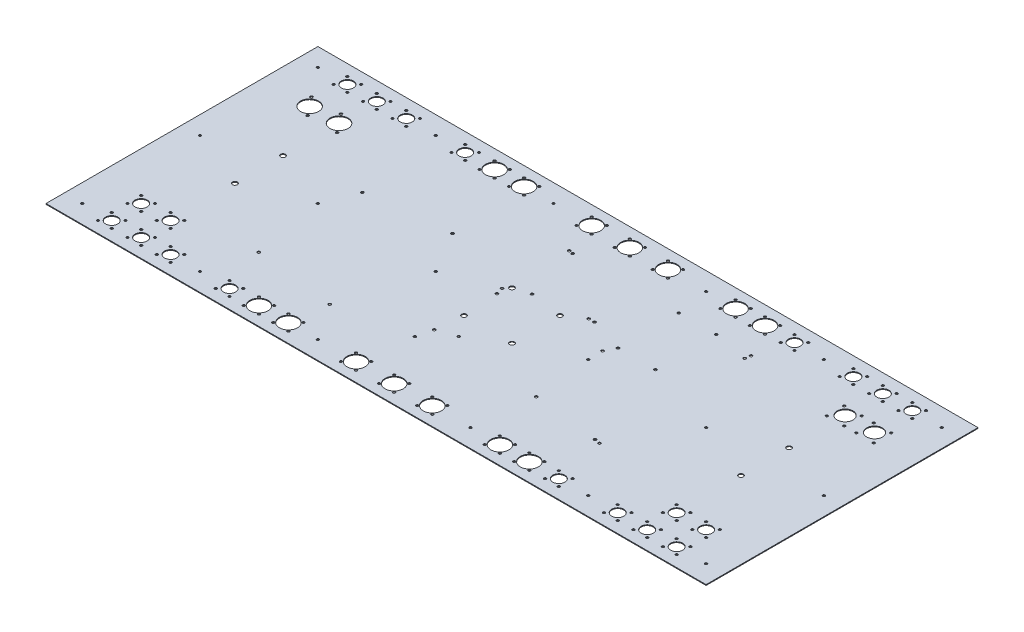
from build123d import *

# Parameters (mm, degrees)
MAIN_PLATE_W        = 874
MAIN_PLATE_H        = 360
BOSS_EXTRUDE1_DEPTH = 1.016
MAIN_HOLES_R        = 1.6
MAIN_HOLES_R_2      = 3.175
CUT_EXTRUDE1_DEPTH  = 473.620389167
FAN_R               = 1.6
FAN_R_2             = 12
CUT_EXTRUDE2_DEPTH  = 474.008271082
NTYPE_R             = 8
NTYPE_R_2           = 1.6
CUT_EXTRUDE3_DEPTH  = 473.620389167
ETHERNET_R          = 12
ETHERNET_R_2        = 1.755
CUT_EXTRUDE6_DEPTH  = 10
POWER_R             = 10.4521
POWER_R_2           = 1.5875
CUT_EXTRUDE7_DEPTH  = 10
ADS9_EVAL_R         = 1.75
CUT_EXTRUDE8_DEPTH  = 10


with BuildPart() as part:
    # main_plate → Boss-Extrude1 (new body)
    with BuildSketch(Plane(origin=(0, 0, 0), x_dir=(1, 0, 0), z_dir=(0, 1, 0))):
        Rectangle(MAIN_PLATE_W, MAIN_PLATE_H)
    extrude(amount=BOSS_EXTRUDE1_DEPTH)

    # main_holes → Cut-Extrude1 (cut, through all)
    with BuildSketch(Plane(origin=(0, 1.016, 0), x_dir=(1, 0, 0), z_dir=(0, 1, 0))):
        with Locations(Location((-413, 156, 0), (0, 0, 270))):
            Circle(MAIN_HOLES_R)
        with Locations(Location((-335, 31.805896398, 0), (0, 0, 270))):
            Circle(MAIN_HOLES_R_2)
        with Locations(Location((-335, -31.805896398, 0), (0, 0, 90))):
            Circle(MAIN_HOLES_R_2)
        with Locations(Location((-257, 156, 0), (0, 0, 270))):
            Circle(MAIN_HOLES_R)
        with Locations(Location((-101, 156, 0), (0, 0, 270))):
            Circle(MAIN_HOLES_R)
        with Locations(Location((-257, 0, 0), (0, 0, 270))):
            Circle(MAIN_HOLES_R)
        with Locations(Location((-101, 0, 0), (0, 0, 270))):
            Circle(MAIN_HOLES_R)
        with Locations(Location((-257, -156, 0), (0, 0, 270))):
            Circle(MAIN_HOLES_R)
        with Locations(Location((-101, -156, 0), (0, 0, 270))):
            Circle(MAIN_HOLES_R)
        with Locations(Location((-413, 0, 0), (0, 0, 270))):
            Circle(MAIN_HOLES_R)
        with Locations(Location((-413, -156, 0), (0, 0, 270))):
            Circle(MAIN_HOLES_R)
        with Locations(Location((-31.75, 31.75, 0), (0, 0, 270))):
            Circle(MAIN_HOLES_R_2)
        with Locations(Location((-31.75, -31.75, 0), (0, 0, 90))):
            Circle(MAIN_HOLES_R_2)
        with Locations(Location((31.75, -31.75, 0), (0, 0, 270))):
            Circle(MAIN_HOLES_R_2)
        with Locations(Location((31.75, 31.75, 0), (0, 0, 90))):
            Circle(MAIN_HOLES_R_2)
        with Locations(Location((413, -156, 0), (0, 0, 90))):
            Circle(MAIN_HOLES_R)
        with Locations(Location((413, 0, 0), (0, 0, 90))):
            Circle(MAIN_HOLES_R)
        with Locations(Location((101, -156, 0), (0, 0, 90))):
            Circle(MAIN_HOLES_R)
        with Locations(Location((257, -156, 0), (0, 0, 90))):
            Circle(MAIN_HOLES_R)
        with Locations(Location((101, 0, 0), (0, 0, 90))):
            Circle(MAIN_HOLES_R)
        with Locations(Location((257, 0, 0), (0, 0, 90))):
            Circle(MAIN_HOLES_R)
        with Locations(Location((101, 156, 0), (0, 0, 90))):
            Circle(MAIN_HOLES_R)
        with Locations(Location((257, 156, 0), (0, 0, 90))):
            Circle(MAIN_HOLES_R)
        with Locations(Location((335, -31.805896398, 0), (0, 0, 270))):
            Circle(MAIN_HOLES_R_2)
        with Locations(Location((335, 31.805896398, 0), (0, 0, 90))):
            Circle(MAIN_HOLES_R_2)
        with Locations(Location((413, 156, 0), (0, 0, 90))):
            Circle(MAIN_HOLES_R)
    extrude(amount=-CUT_EXTRUDE1_DEPTH, mode=Mode.SUBTRACT)

    # fan → Cut-Extrude2 (cut, through all)
    with BuildSketch(Plane(origin=(0, 1.016, 1.016), x_dir=(1, 0, 0), z_dir=(0, 1, 0))):
        with Locations(Location((130, -144.984, 0), (0, 0, 270))):
            Circle(FAN_R)
        with Locations(Location((150, -144.984, 0), (0, 0, 270))):
            Circle(FAN_R)
        with Locations(Location((150, -164.984, 0), (0, 0, 270))):
            Circle(FAN_R)
        with Locations(Location((130, -164.984, 0), (0, 0, 270))):
            Circle(FAN_R)
        with Locations(Location((140, -154.984, 0), (0, 0, 270))):
            Circle(FAN_R_2)
        with Locations(Location((169, -144.984, 0), (0, 0, 270))):
            Circle(FAN_R)
        with Locations(Location((189, -144.984, 0), (0, 0, 270))):
            Circle(FAN_R)
        with Locations(Location((189, -164.984, 0), (0, 0, 270))):
            Circle(FAN_R)
        with Locations(Location((169, -164.984, 0), (0, 0, 270))):
            Circle(FAN_R)
        with Locations(Location((179, -154.984, 0), (0, 0, 270))):
            Circle(FAN_R_2)
        with Locations(Location((-10, -144.984, 0), (0, 0, 270))):
            Circle(FAN_R)
        with Locations(Location((10, -144.984, 0), (0, 0, 270))):
            Circle(FAN_R)
        with Locations(Location((10, -164.984, 0), (0, 0, 270))):
            Circle(FAN_R)
        with Locations(Location((-10, -164.984, 0), (0, 0, 270))):
            Circle(FAN_R)
        with Locations(Location((0, -154.984, 0), (0, 0, 270))):
            Circle(FAN_R_2)
        with Locations(Location((-60.5, -144.984, 0), (0, 0, 270))):
            Circle(FAN_R)
        with Locations(Location((-40.5, -144.984, 0), (0, 0, 270))):
            Circle(FAN_R)
        with Locations(Location((-40.5, -164.984, 0), (0, 0, 270))):
            Circle(FAN_R)
        with Locations(Location((-60.5, -164.984, 0), (0, 0, 270))):
            Circle(FAN_R)
        with Locations(Location((-50.5, -154.984, 0), (0, 0, 270))):
            Circle(FAN_R_2)
        with Locations(Location((40.5, -144.984, 0), (0, 0, 270))):
            Circle(FAN_R)
        with Locations(Location((60.5, -144.984, 0), (0, 0, 270))):
            Circle(FAN_R)
        with Locations(Location((60.5, -164.984, 0), (0, 0, 270))):
            Circle(FAN_R)
        with Locations(Location((40.5, -164.984, 0), (0, 0, 270))):
            Circle(FAN_R)
        with Locations(Location((50.5, -154.984, 0), (0, 0, 270))):
            Circle(FAN_R_2)
        with Locations(Location((-10, 167.016, 0), (0, 0, 270))):
            Circle(FAN_R)
        with Locations(Location((10, 167.016, 0), (0, 0, 270))):
            Circle(FAN_R)
        with Locations(Location((10, 147.016, 0), (0, 0, 270))):
            Circle(FAN_R)
        with Locations(Location((-10, 147.016, 0), (0, 0, 270))):
            Circle(FAN_R)
        with Locations(Location((0, 157.016, 0), (0, 0, 270))):
            Circle(FAN_R_2)
        with Locations(Location((-60.5, 167.016, 0), (0, 0, 270))):
            Circle(FAN_R)
        with Locations(Location((-40.5, 167.016, 0), (0, 0, 270))):
            Circle(FAN_R)
        with Locations(Location((-40.5, 147.016, 0), (0, 0, 270))):
            Circle(FAN_R)
        with Locations(Location((-60.5, 147.016, 0), (0, 0, 270))):
            Circle(FAN_R)
        with Locations(Location((-50.5, 157.016, 0), (0, 0, 270))):
            Circle(FAN_R_2)
        with Locations(Location((40.5, 167.016, 0), (0, 0, 270))):
            Circle(FAN_R)
        with Locations(Location((60.5, 167.016, 0), (0, 0, 270))):
            Circle(FAN_R)
        with Locations(Location((60.5, 147.016, 0), (0, 0, 270))):
            Circle(FAN_R)
        with Locations(Location((40.5, 147.016, 0), (0, 0, 270))):
            Circle(FAN_R)
        with Locations(Location((50.5, 157.016, 0), (0, 0, 270))):
            Circle(FAN_R_2)
        with Locations(Location((-189, -144.984, 0), (0, 0, 270))):
            Circle(FAN_R)
        with Locations(Location((-169, -144.984, 0), (0, 0, 270))):
            Circle(FAN_R)
        with Locations(Location((-169, -164.984, 0), (0, 0, 270))):
            Circle(FAN_R)
        with Locations(Location((-189, -164.984, 0), (0, 0, 270))):
            Circle(FAN_R)
        with Locations(Location((-179, -154.984, 0), (0, 0, 270))):
            Circle(FAN_R_2)
        with Locations(Location((-150, -144.984, 0), (0, 0, 270))):
            Circle(FAN_R)
        with Locations(Location((-130, -144.984, 0), (0, 0, 270))):
            Circle(FAN_R)
        with Locations(Location((-130, -164.984, 0), (0, 0, 270))):
            Circle(FAN_R)
        with Locations(Location((-150, -164.984, 0), (0, 0, 270))):
            Circle(FAN_R)
        with Locations(Location((-140, -154.984, 0), (0, 0, 270))):
            Circle(FAN_R_2)
        with Locations(Location((-189, 167.016, 0), (0, 0, 270))):
            Circle(FAN_R)
        with Locations(Location((-169, 167.016, 0), (0, 0, 270))):
            Circle(FAN_R)
        with Locations(Location((-169, 147.016, 0), (0, 0, 270))):
            Circle(FAN_R)
        with Locations(Location((-189, 147.016, 0), (0, 0, 270))):
            Circle(FAN_R)
        with Locations(Location((-179, 157.016, 0), (0, 0, 270))):
            Circle(FAN_R_2)
        with Locations(Location((-150, 167.016, 0), (0, 0, 270))):
            Circle(FAN_R)
        with Locations(Location((-130, 167.016, 0), (0, 0, 270))):
            Circle(FAN_R)
        with Locations(Location((-130, 147.016, 0), (0, 0, 270))):
            Circle(FAN_R)
        with Locations(Location((-150, 147.016, 0), (0, 0, 270))):
            Circle(FAN_R)
        with Locations(Location((-140, 157.016, 0), (0, 0, 270))):
            Circle(FAN_R_2)
        with Locations(Location((130, 167.016, 0), (0, 0, 270))):
            Circle(FAN_R)
        with Locations(Location((150, 167.016, 0), (0, 0, 270))):
            Circle(FAN_R)
        with Locations(Location((150, 147.016, 0), (0, 0, 270))):
            Circle(FAN_R)
        with Locations(Location((130, 147.016, 0), (0, 0, 270))):
            Circle(FAN_R)
        with Locations(Location((140, 157.016, 0), (0, 0, 270))):
            Circle(FAN_R_2)
        with Locations(Location((169, 167.016, 0), (0, 0, 270))):
            Circle(FAN_R)
        with Locations(Location((189, 167.016, 0), (0, 0, 270))):
            Circle(FAN_R)
        with Locations(Location((189, 147.016, 0), (0, 0, 270))):
            Circle(FAN_R)
        with Locations(Location((169, 147.016, 0), (0, 0, 270))):
            Circle(FAN_R)
        with Locations(Location((179, 157.016, 0), (0, 0, 270))):
            Circle(FAN_R_2)
    extrude(amount=-CUT_EXTRUDE2_DEPTH, mode=Mode.SUBTRACT)

    # ntype → Cut-Extrude3 (cut, through all)
    with BuildSketch(Plane(origin=(0, 1.016, 0), x_dir=(1, 0, 0), z_dir=(0, 1, 0))):
        with Locations(Location((-218, 156, 0), (0, 0, 270))):
            Circle(NTYPE_R)
        with Locations(Location((-227.1, 165.1, 0), (0, 0, 270))):
            Circle(NTYPE_R_2)
        with Locations(Location((-208.9, 165.1, 0), (0, 0, 270))):
            Circle(NTYPE_R_2)
        with Locations(Location((-208.9, 146.9, 0), (0, 0, 270))):
            Circle(NTYPE_R_2)
        with Locations(Location((-227.1, 146.9, 0), (0, 0, 270))):
            Circle(NTYPE_R_2)
        with Locations(Location((218, 156, 0), (0, 0, 270))):
            Circle(NTYPE_R)
        with Locations(Location((208.9, 165.1, 0), (0, 0, 270))):
            Circle(NTYPE_R_2)
        with Locations(Location((227.1, 165.1, 0), (0, 0, 270))):
            Circle(NTYPE_R_2)
        with Locations(Location((227.1, 146.9, 0), (0, 0, 270))):
            Circle(NTYPE_R_2)
        with Locations(Location((208.9, 146.9, 0), (0, 0, 270))):
            Circle(NTYPE_R_2)
        with Locations(Location((-218, -156, 0), (0, 0, 270))):
            Circle(NTYPE_R)
        with Locations(Location((-227.1, -146.9, 0), (0, 0, 270))):
            Circle(NTYPE_R_2)
        with Locations(Location((-208.9, -146.9, 0), (0, 0, 270))):
            Circle(NTYPE_R_2)
        with Locations(Location((-208.9, -165.1, 0), (0, 0, 270))):
            Circle(NTYPE_R_2)
        with Locations(Location((-227.1, -165.1, 0), (0, 0, 270))):
            Circle(NTYPE_R_2)
        with Locations(Location((218, -156, 0), (0, 0, 270))):
            Circle(NTYPE_R)
        with Locations(Location((208.9, -146.9, 0), (0, 0, 270))):
            Circle(NTYPE_R_2)
        with Locations(Location((227.1, -146.9, 0), (0, 0, 270))):
            Circle(NTYPE_R_2)
        with Locations(Location((227.1, -165.1, 0), (0, 0, 270))):
            Circle(NTYPE_R_2)
        with Locations(Location((208.9, -165.1, 0), (0, 0, 270))):
            Circle(NTYPE_R_2)
        with Locations(Location((-374, 156, 0), (0, 0, 270))):
            Circle(NTYPE_R)
        with Locations(Location((-383.1, 165.1, 0), (0, 0, 270))):
            Circle(NTYPE_R_2)
        with Locations(Location((-364.9, 165.1, 0), (0, 0, 270))):
            Circle(NTYPE_R_2)
        with Locations(Location((-364.9, 146.9, 0), (0, 0, 270))):
            Circle(NTYPE_R_2)
        with Locations(Location((-383.1, 146.9, 0), (0, 0, 270))):
            Circle(NTYPE_R_2)
        with Locations(Location((-296, 156, 0), (0, 0, 270))):
            Circle(NTYPE_R)
        with Locations(Location((-305.1, 165.1, 0), (0, 0, 270))):
            Circle(NTYPE_R_2)
        with Locations(Location((-286.9, 165.1, 0), (0, 0, 270))):
            Circle(NTYPE_R_2)
        with Locations(Location((-286.9, 146.9, 0), (0, 0, 270))):
            Circle(NTYPE_R_2)
        with Locations(Location((-305.1, 146.9, 0), (0, 0, 270))):
            Circle(NTYPE_R_2)
        with Locations(Location((-335, 156, 0), (0, 0, 270))):
            Circle(NTYPE_R)
        with Locations(Location((-344.1, 165.1, 0), (0, 0, 270))):
            Circle(NTYPE_R_2)
        with Locations(Location((-325.9, 165.1, 0), (0, 0, 270))):
            Circle(NTYPE_R_2)
        with Locations(Location((-325.9, 146.9, 0), (0, 0, 270))):
            Circle(NTYPE_R_2)
        with Locations(Location((-344.1, 146.9, 0), (0, 0, 270))):
            Circle(NTYPE_R_2)
        with Locations(Location((296, -156, 0), (0, 0, 270))):
            Circle(NTYPE_R)
        with Locations(Location((286.9, -146.9, 0), (0, 0, 270))):
            Circle(NTYPE_R_2)
        with Locations(Location((305.1, -146.9, 0), (0, 0, 270))):
            Circle(NTYPE_R_2)
        with Locations(Location((305.1, -165.1, 0), (0, 0, 270))):
            Circle(NTYPE_R_2)
        with Locations(Location((286.9, -165.1, 0), (0, 0, 270))):
            Circle(NTYPE_R_2)
        with Locations(Location((374, -156, 0), (0, 0, 270))):
            Circle(NTYPE_R)
        with Locations(Location((364.9, -146.9, 0), (0, 0, 270))):
            Circle(NTYPE_R_2)
        with Locations(Location((383.1, -146.9, 0), (0, 0, 270))):
            Circle(NTYPE_R_2)
        with Locations(Location((383.1, -165.1, 0), (0, 0, 270))):
            Circle(NTYPE_R_2)
        with Locations(Location((364.9, -165.1, 0), (0, 0, 270))):
            Circle(NTYPE_R_2)
        with Locations(Location((335, -156, 0), (0, 0, 270))):
            Circle(NTYPE_R)
        with Locations(Location((325.9, -146.9, 0), (0, 0, 270))):
            Circle(NTYPE_R_2)
        with Locations(Location((344.1, -146.9, 0), (0, 0, 270))):
            Circle(NTYPE_R_2)
        with Locations(Location((344.1, -165.1, 0), (0, 0, 270))):
            Circle(NTYPE_R_2)
        with Locations(Location((325.9, -165.1, 0), (0, 0, 270))):
            Circle(NTYPE_R_2)
        with Locations(Location((296, 156, 0), (0, 0, 270))):
            Circle(NTYPE_R)
        with Locations(Location((286.9, 165.1, 0), (0, 0, 270))):
            Circle(NTYPE_R_2)
        with Locations(Location((305.1, 165.1, 0), (0, 0, 270))):
            Circle(NTYPE_R_2)
        with Locations(Location((305.1, 146.9, 0), (0, 0, 270))):
            Circle(NTYPE_R_2)
        with Locations(Location((286.9, 146.9, 0), (0, 0, 270))):
            Circle(NTYPE_R_2)
        with Locations(Location((374, 156, 0), (0, 0, 270))):
            Circle(NTYPE_R)
        with Locations(Location((364.9, 165.1, 0), (0, 0, 270))):
            Circle(NTYPE_R_2)
        with Locations(Location((383.1, 165.1, 0), (0, 0, 270))):
            Circle(NTYPE_R_2)
        with Locations(Location((383.1, 146.9, 0), (0, 0, 270))):
            Circle(NTYPE_R_2)
        with Locations(Location((364.9, 146.9, 0), (0, 0, 270))):
            Circle(NTYPE_R_2)
        with Locations(Location((335, 156, 0), (0, 0, 270))):
            Circle(NTYPE_R)
        with Locations(Location((325.9, 165.1, 0), (0, 0, 270))):
            Circle(NTYPE_R_2)
        with Locations(Location((344.1, 165.1, 0), (0, 0, 270))):
            Circle(NTYPE_R_2)
        with Locations(Location((344.1, 146.9, 0), (0, 0, 270))):
            Circle(NTYPE_R_2)
        with Locations(Location((325.9, 146.9, 0), (0, 0, 270))):
            Circle(NTYPE_R_2)
        with Locations(Location((-374, -156, 0), (0, 0, 270))):
            Circle(NTYPE_R)
        with Locations(Location((-383.1, -146.9, 0), (0, 0, 270))):
            Circle(NTYPE_R_2)
        with Locations(Location((-364.9, -146.9, 0), (0, 0, 270))):
            Circle(NTYPE_R_2)
        with Locations(Location((-364.9, -165.1, 0), (0, 0, 270))):
            Circle(NTYPE_R_2)
        with Locations(Location((-383.1, -165.1, 0), (0, 0, 270))):
            Circle(NTYPE_R_2)
        with Locations(Location((-296, -156, 0), (0, 0, 270))):
            Circle(NTYPE_R)
        with Locations(Location((-305.1, -146.9, 0), (0, 0, 270))):
            Circle(NTYPE_R_2)
        with Locations(Location((-286.9, -146.9, 0), (0, 0, 270))):
            Circle(NTYPE_R_2)
        with Locations(Location((-286.9, -165.1, 0), (0, 0, 270))):
            Circle(NTYPE_R_2)
        with Locations(Location((-305.1, -165.1, 0), (0, 0, 270))):
            Circle(NTYPE_R_2)
        with Locations(Location((-335, -156, 0), (0, 0, 270))):
            Circle(NTYPE_R)
        with Locations(Location((-344.1, -146.9, 0), (0, 0, 270))):
            Circle(NTYPE_R_2)
        with Locations(Location((-325.9, -146.9, 0), (0, 0, 270))):
            Circle(NTYPE_R_2)
        with Locations(Location((-325.9, -165.1, 0), (0, 0, 270))):
            Circle(NTYPE_R_2)
        with Locations(Location((-344.1, -165.1, 0), (0, 0, 270))):
            Circle(NTYPE_R_2)
        with Locations(Location((-335, -117, 0), (0, 0, 270))):
            Circle(NTYPE_R)
        with Locations(Location((-344.1, -107.9, 0), (0, 0, 270))):
            Circle(NTYPE_R_2)
        with Locations(Location((-325.9, -107.9, 0), (0, 0, 270))):
            Circle(NTYPE_R_2)
        with Locations(Location((-325.9, -126.1, 0), (0, 0, 270))):
            Circle(NTYPE_R_2)
        with Locations(Location((-344.1, -126.1, 0), (0, 0, 270))):
            Circle(NTYPE_R_2)
        with Locations(Location((-374, -117, 0), (0, 0, 270))):
            Circle(NTYPE_R)
        with Locations(Location((-383.1, -107.9, 0), (0, 0, 270))):
            Circle(NTYPE_R_2)
        with Locations(Location((-364.9, -107.9, 0), (0, 0, 270))):
            Circle(NTYPE_R_2)
        with Locations(Location((-364.9, -126.1, 0), (0, 0, 270))):
            Circle(NTYPE_R_2)
        with Locations(Location((-383.1, -126.1, 0), (0, 0, 270))):
            Circle(NTYPE_R_2)
        with Locations(Location((374, -117, 0), (0, 0, 270))):
            Circle(NTYPE_R)
        with Locations(Location((364.9, -107.9, 0), (0, 0, 270))):
            Circle(NTYPE_R_2)
        with Locations(Location((383.1, -107.9, 0), (0, 0, 270))):
            Circle(NTYPE_R_2)
        with Locations(Location((383.1, -126.1, 0), (0, 0, 270))):
            Circle(NTYPE_R_2)
        with Locations(Location((364.9, -126.1, 0), (0, 0, 270))):
            Circle(NTYPE_R_2)
        with Locations(Location((335, -117, 0), (0, 0, 270))):
            Circle(NTYPE_R)
        with Locations(Location((325.9, -107.9, 0), (0, 0, 270))):
            Circle(NTYPE_R_2)
        with Locations(Location((344.1, -107.9, 0), (0, 0, 270))):
            Circle(NTYPE_R_2)
        with Locations(Location((344.1, -126.1, 0), (0, 0, 270))):
            Circle(NTYPE_R_2)
        with Locations(Location((325.9, -126.1, 0), (0, 0, 270))):
            Circle(NTYPE_R_2)
    extrude(amount=-CUT_EXTRUDE3_DEPTH, mode=Mode.SUBTRACT)

    # ethernet → Cut-Extrude6 (cut)
    with BuildSketch(Plane(origin=(0, 1.016, 0), x_dir=(1, 0, 0), z_dir=(0, 1, 0))):
        with Locations(Location((-374, 106, 0), (0, 0, 270))):
            Circle(ETHERNET_R)
        with Locations(Location((-383.5, 118, 0), (0, 0, 270))):
            Circle(ETHERNET_R_2)
        with Locations(Location((-364.5, 94, 0), (0, 0, 270))):
            Circle(ETHERNET_R_2)
        with Locations(Location((-335, 106, 0), (0, 0, 270))):
            Circle(ETHERNET_R)
        with Locations(Location((-344.5, 118, 0), (0, 0, 270))):
            Circle(ETHERNET_R_2)
        with Locations(Location((-325.5, 94, 0), (0, 0, 270))):
            Circle(ETHERNET_R_2)
    extrude(amount=-CUT_EXTRUDE6_DEPTH, mode=Mode.SUBTRACT)

    # power → Cut-Extrude7 (cut)
    with BuildSketch(Plane(origin=(0, 1.016, 0), x_dir=(1, 0, 0), z_dir=(0, 1, 0))):
        with Locations(Location((374, 106, 0), (0, 0, 270))):
            Circle(POWER_R)
        with Locations(Location((362.4938, 116.4521, 0), (0, 0, 270))):
            Circle(POWER_R_2)
        with Locations(Location((385.5062, 116.4521, 0), (0, 0, 270))):
            Circle(POWER_R_2)
        with Locations(Location((385.5062, 93.4397, 0), (0, 0, 270))):
            Circle(POWER_R_2)
        with Locations(Location((362.4938, 93.4397, 0), (0, 0, 270))):
            Circle(POWER_R_2)
        with Locations(Location((335, 106, 0), (0, 0, 270))):
            Circle(POWER_R)
        with Locations(Location((323.4938, 116.4521, 0), (0, 0, 270))):
            Circle(POWER_R_2)
        with Locations(Location((346.5062, 116.4521, 0), (0, 0, 270))):
            Circle(POWER_R_2)
        with Locations(Location((346.5062, 93.4397, 0), (0, 0, 270))):
            Circle(POWER_R_2)
        with Locations(Location((323.4938, 93.4397, 0), (0, 0, 270))):
            Circle(POWER_R_2)
    extrude(amount=-CUT_EXTRUDE7_DEPTH, mode=Mode.SUBTRACT)

    # ads9+eval → Cut-Extrude8 (cut)
    with BuildSketch(Plane(origin=(0, 1.016, -2.032), x_dir=(-1, 0, 0), z_dir=(0, 1, 0))):
        with Locations(Location((-204.363065117, 90.500336649, 0), (0, 0, 90))):
            Circle(ADS9_EVAL_R)
        with Locations(Location((-197.123065117, 89.180336649, 0), (0, 0, 90))):
            Circle(ADS9_EVAL_R)
        with Locations(Location((-203.103065117, -102.979663351, 0), (0, 0, 90))):
            Circle(ADS9_EVAL_R)
        with Locations(Location((-204.373065117, -110.159663351, 0), (0, 0, 90))):
            Circle(ADS9_EVAL_R)
        with Locations(Location((-62.133065117, -45.069663351, 0), (0, 0, 90))):
            Circle(ADS9_EVAL_R)
        with Locations(Location((-54.513065117, -45.069663351, 0), (0, 0, 90))):
            Circle(ADS9_EVAL_R)
        with Locations(Location((11.346934883, -35.819663351, 0), (0, 0, 90))):
            Circle(ADS9_EVAL_R)
        with Locations(Location((-100.413065117, -17.439663351, 0), (0, 0, 90))):
            Circle(ADS9_EVAL_R)
        with Locations(Location((37.736934883, -22.529663351, 0), (0, 0, 90))):
            Circle(ADS9_EVAL_R)
        with Locations(Location((35.026934883, -13.059663351, 0), (0, 0, 90))):
            Circle(ADS9_EVAL_R)
        with Locations(Location((30.826934883, -109.199663351, 0), (0, 0, 90))):
            Circle(ADS9_EVAL_R)
        with Locations(Location((36.469371781, -110.159663351, 0), (0, 0, 90))):
            Circle(ADS9_EVAL_R)
        with Locations(Location((11.356934883, 61.210336649, 0), (0, 0, 90))):
            Circle(ADS9_EVAL_R)
        with Locations(Location((35.186934883, 69.740336649, 0), (0, 0, 90))):
            Circle(ADS9_EVAL_R)
        with Locations(Location((40.106934883, 90.500336649, 0), (0, 0, 90))):
            Circle(ADS9_EVAL_R)
        with Locations(Location((-109.113065117, 79.110336649, 0), (0, 0, 90))):
            Circle(ADS9_EVAL_R)
        with Locations(Location((133.556582069, 109.846454569, 0), (0, 0, 90))):
            Circle(ADS9_EVAL_R)
        with Locations(Location((240.236582069, 97.089220982, 0), (0, 0, 90))):
            Circle(ADS9_EVAL_R)
        with Locations(Location((240.162998389, -40.07075928, 0), (0, 0, 90))):
            Circle(ADS9_EVAL_R)
        with Locations(Location((133.469371781, -52.713522038, 0), (0, 0, 90))):
            Circle(ADS9_EVAL_R)
        with Locations(Location((-157.002065117, -111.366163351, 0), (0, 0, 90))):
            Circle(ADS9_EVAL_R)
        with Locations(Location((-107.472065117, -111.366163351, 0), (0, 0, 90))):
            Circle(ADS9_EVAL_R)
        with Locations(Location((-157.002065117, -30.848163351, 0), (0, 0, 90))):
            Circle(ADS9_EVAL_R)
        with Locations(Location((-107.472065117, -30.848163351, 0), (0, 0, 90))):
            Circle(ADS9_EVAL_R)
    extrude(amount=-CUT_EXTRUDE8_DEPTH, mode=Mode.SUBTRACT)


solid = part.part
